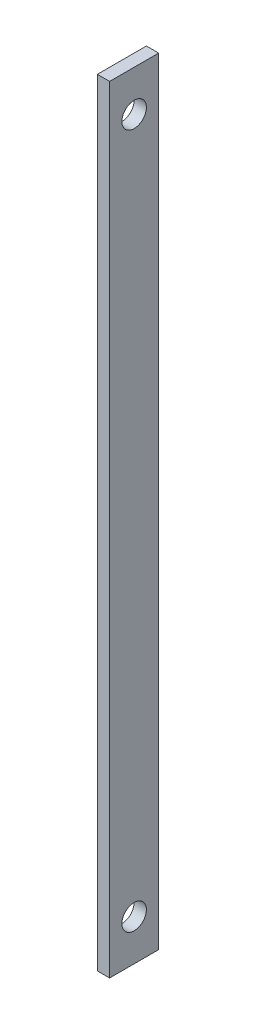
from build123d import *

# Parameters (mm, degrees)
SKETCH1_W           = 12
SKETCH1_H           = 190
BOSS_EXTRUDE1_DEPTH = 3
SKETCH2_R           = 3
CUT_EXTRUDE1_DEPTH  = 3


with BuildPart() as part:
    # Sketch1 → Boss-Extrude1 (new body)
    with BuildSketch(Plane(origin=(0, 0, 0), x_dir=(0, 0, -1), z_dir=(1, 0, 0))):
        Rectangle(SKETCH1_W, SKETCH1_H)
    extrude(amount=BOSS_EXTRUDE1_DEPTH)

    # Sketch2 → Cut-Extrude1 (cut)
    with BuildSketch(Plane.ZY):
        with Locations((0, 85)):
            Circle(SKETCH2_R)
        with Locations((0, -85)):
            Circle(SKETCH2_R)
    extrude(amount=-CUT_EXTRUDE1_DEPTH, mode=Mode.SUBTRACT)


solid = part.part
